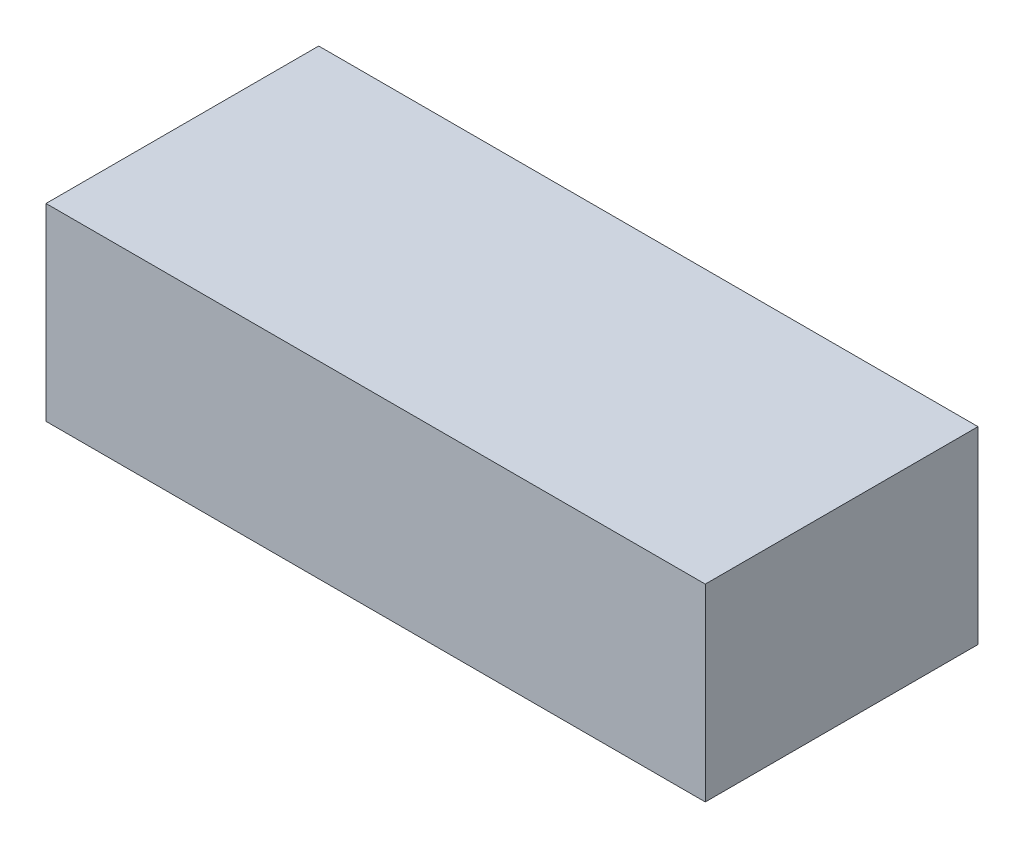
from build123d import *

# Parameters (mm, degrees)
CROQUIS1_W              = 70.104
CROQUIS1_H              = 29
SALIENTE_EXTRUIR1_DEPTH = 20.066


with BuildPart() as part:
    # Croquis1 → Saliente-Extruir1 (new body)
    with BuildSketch(Plane(origin=(0, 0, 0), x_dir=(1, 0, 0), z_dir=(0, 1, 0))):
        Rectangle(CROQUIS1_W, CROQUIS1_H)
    extrude(amount=SALIENTE_EXTRUIR1_DEPTH)


solid = part.part
